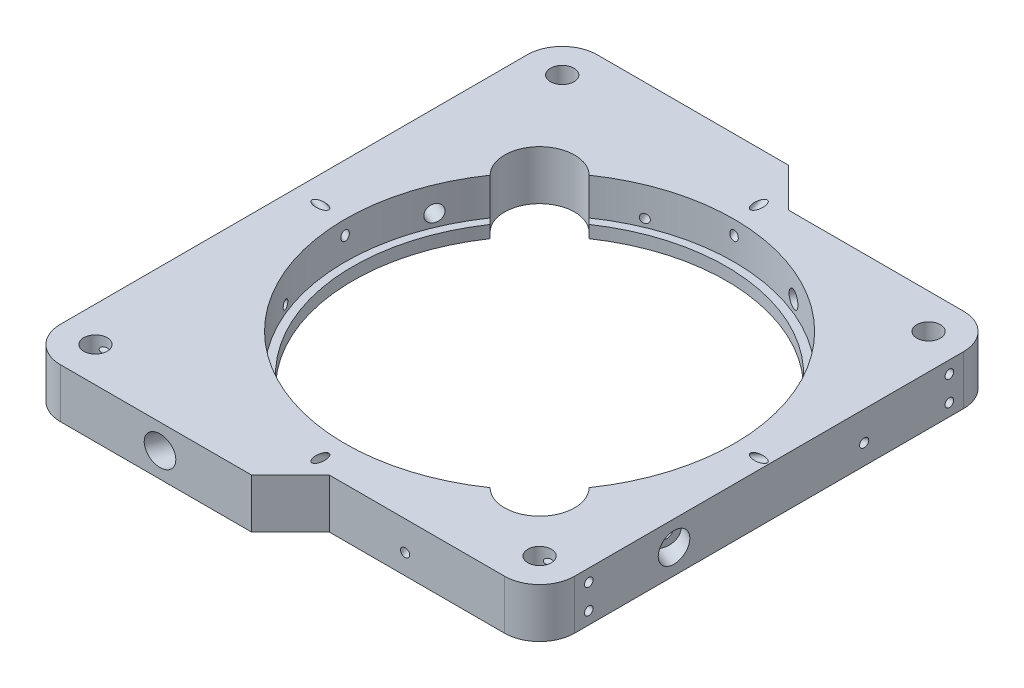
from build123d import *

# Parameters (mm, degrees)
SKETCH1_R                           = 3.025
BOSS_EXTRUDE1_DEPTH                 = 12.7
SKETCH2_R                           = 1.095
CUT_EXTRUDE1_DEPTH                  = 15
SKETCH5_R                           = 2.1
CUT_EXTRUDE2_DEPTH                  = 95.415667708
SKETCH6_R                           = 1.095
CUT_EXTRUDE3_DEPTH                  = 95.415667708
CUT_EXTRUDE4_REACH                  = 134.175
SKETCH7_R                           = 1.095
CUT_EXTRUDE4_DIRECTION_2_REACH      = 134.175
CUT_EXTRUDE4_DIRECTION_2_END_RADIUS = 50
CIRPATTERN1_COUNT                   = 4
CUT_EXTRUDE5_DEPTH                  = 95.415667848
CIRPATTERN2_COUNT                   = 2
CUT_EXTRUDE6_START                  = -158.748997848
SKETCH9_R                           = 3.75
CUT_EXTRUDE6_DEPTH                  = 100.415667848
CIRPATTERN6_COUNT                   = 4
SKETCH10_R                          = 1.095
CUT_EXTRUDE7_DEPTH                  = 16


with BuildPart() as part:
    # Sketch1 → Boss-Extrude1 (new body)
    with BuildSketch(Plane(origin=(0, 0, 0), x_dir=(1, 0, 0), z_dir=(0, 1, 0))):
        with BuildLine():
            Line((5, 59), (50, 59))
            ThreePointArc((50, 59), (56.363961031, 56.363961031), (59, 50))
            Line((59, 50), (59, -50))
            ThreePointArc((59, -50), (56.363961031, -56.363961031), (50, -59))
            Line((50, -59), (5, -59))
            Line((5, -59), (-5, -69))
            Line((-5, -69), (-54.1825, -69))
            ThreePointArc((-54.1825, -69), (-60.546461031, -66.363961031), (-63.1825, -60))
            Line((-63.1825, -60), (-63.1825, 60))
            ThreePointArc((-63.1825, 60), (-60.546461031, 66.363961031), (-54.1825, 69))
            Line((-54.1825, 69), (-5, 69))
            Line((-5, 69), (5, 59))
        make_face()
        with Locations(Location((50, 50, 0), (0, 0, 270))):
            Circle(SKETCH1_R, mode=Mode.SUBTRACT)
        with Locations(Location((50, -50, 0), (0, 0, 270))):
            Circle(SKETCH1_R, mode=Mode.SUBTRACT)
        with Locations(Location((-54.1825, 60, 0), (0, 0, 270))):
            Circle(SKETCH1_R, mode=Mode.SUBTRACT)
        with Locations(Location((-54.1825, -60, 0), (0, 0, 270))):
            Circle(SKETCH1_R, mode=Mode.SUBTRACT)
    extrude(amount=BOSS_EXTRUDE1_DEPTH)

    # Sketch2 → Cut-Extrude1 (cut)
    with BuildSketch(Plane(origin=(59, 0, 0), x_dir=(0, 0, -1), z_dir=(1, 0, 0))):
        with Locations((-46.34, 9.525)):
            Circle(SKETCH2_R)
        with Locations((-46.34, 3.175)):
            Circle(SKETCH2_R)
        with Locations((46.34, 9.525)):
            Circle(SKETCH2_R)
        with Locations((46.34, 3.175)):
            Circle(SKETCH2_R)
    extrude(amount=-CUT_EXTRUDE1_DEPTH, mode=Mode.SUBTRACT)

    # Sketch4 → Cut-Revolve1 (revolve, cut)
    with BuildSketch(Plane.XY):
        Polygon((0, 0), (0, 12.7), (50, 12.7), (50, 3.175), (48, 3.175), (48, 0), align=None)
    revolve(axis=Axis((0, 0, 0), (0, 1, 0)), mode=Mode.SUBTRACT)

    # Sketch5 → Cut-Extrude2 (cut, through all)
    with BuildSketch(Plane(origin=(0, 0, 0), x_dir=(0.9238795325112865, 0, 0.3826834323650906), z_dir=(-0.38268343236509056, 0, 0.9238795325112864))):
        with Locations((0, 6.35)):
            Circle(SKETCH5_R)
    cut_extrude2 = extrude(amount=-CUT_EXTRUDE2_DEPTH, mode=Mode.SUBTRACT)

    # Sketch6 → Cut-Extrude3 (cut, through all)
    with BuildSketch(Plane(origin=(0, 0, 0), x_dir=(0.3826834323650874, 0, 0.9238795325112878), z_dir=(-0.9238795325112878, 0, 0.3826834323650874))):
        with Locations((0, 5.175)):
            Circle(SKETCH6_R)
    cut_extrude3 = extrude(amount=-CUT_EXTRUDE3_DEPTH, mode=Mode.SUBTRACT)

    # Cut-Extrude4: up to this plane
    cut_extrude4_end = Plane(origin=(-54.1825, 12.7, -60), z_dir=(0, 1, 0))
    # Sketch7 → Cut-Extrude4 (cut, up to the surface)
    with BuildSketch(Plane(origin=(0, 25.547749412, 44.25), x_dir=(-1, 0, 0), z_dir=(0, -0.500000000000001, -0.866025403784438)), mode=Mode.PRIVATE) as cut_extrude4_sk1:
        with Locations(Location((0, -17.176477372, 0), (0, 0, 90))):
            Circle(SKETCH7_R)
    cut_extrude4_tool1 = split(extrude(cut_extrude4_sk1.sketch, amount=-CUT_EXTRUDE4_REACH, mode=Mode.PRIVATE), bisect_by=cut_extrude4_end, keep=Keep.BOTH, mode=Mode.PRIVATE)
    cut_extrude4 = cut_extrude4_tool1.solids().sort_by_distance((0, 10.672484, 52.838239))[0]
    add(cut_extrude4, mode=Mode.SUBTRACT)

    # Cut-Extrude4 direction 2: up to this cylinder (the profile starts outside it)
    cut_extrude4_direction_2_end = Plane(origin=(0, 10.672484, 0), z_dir=(0, -1, 0)) * Cylinder(CUT_EXTRUDE4_DIRECTION_2_END_RADIUS, 369.35, mode=Mode.PRIVATE)
    # Sketch7 → Cut-Extrude4 direction 2 (cut, up to the surface)
    with BuildSketch(Plane(origin=(0, 25.547749412, 44.25), x_dir=(-1, 0, 0), z_dir=(0, -0.500000000000001, -0.866025403784438)), mode=Mode.PRIVATE) as cut_extrude4_direction_2_sk1:
        with Locations(Location((0, -17.176477372, 0), (0, 0, 90))):
            Circle(SKETCH7_R)
    cut_extrude4_direction_2_tool1 = extrude(cut_extrude4_direction_2_sk1.sketch, amount=CUT_EXTRUDE4_DIRECTION_2_REACH, mode=Mode.PRIVATE) - cut_extrude4_direction_2_end
    cut_extrude4_direction_2 = cut_extrude4_direction_2_tool1.solids().sort_by_distance((0, 10.672484, 52.838239))[0]
    add(cut_extrude4_direction_2, mode=Mode.SUBTRACT)
    cut_extrude4 = cut_extrude4 + cut_extrude4_direction_2  # both directions under the feature's name, for the pattern or mirror that repeats it

    # CirPattern1: Cut-Extrude2, Cut-Extrude3, Cut-Extrude4 ×4 about axis
    cirpattern1_axis = Axis((0, 13.335, 0), (0, -1, 0))
    add([cut_extrude2.rotate(cirpattern1_axis, i * 360 / CIRPATTERN1_COUNT) for i in range(1, CIRPATTERN1_COUNT)], mode=Mode.SUBTRACT)
    add([cut_extrude3.rotate(cirpattern1_axis, i * 360 / CIRPATTERN1_COUNT) for i in range(1, CIRPATTERN1_COUNT)], mode=Mode.SUBTRACT)
    add([cut_extrude4.rotate(cirpattern1_axis, i * 360 / CIRPATTERN1_COUNT) for i in range(1, CIRPATTERN1_COUNT)], mode=Mode.SUBTRACT)

    # Sketch8 → Cut-Extrude5 (cut, through all)
    with BuildSketch(Plane(origin=(0, 12.7, 0), x_dir=(1, 0, 0), z_dir=(0, 1, 0))):
        with BuildLine():
            Line((-41.141827555, 28.413905494), (-39.703127187, 26.975205126))
            Line((-39.703127187, 26.975205126), (-26.975205126, 39.703127187))
            Line((-26.975205126, 39.703127187), (-28.413905494, 41.141827555))
            ThreePointArc((-28.413905494, 41.141827555), (-41.141827555, 41.141827555), (-41.141827555, 28.413905494))
        make_face()
    cut_extrude5 = extrude(amount=-CUT_EXTRUDE5_DEPTH, mode=Mode.SUBTRACT)

    # CirPattern2: Cut-Extrude5 ×2 about axis
    cirpattern2_axis = Axis((0, 0, 0), (0, 1, 0))
    for i in range(1, CIRPATTERN2_COUNT):
        add(cut_extrude5.rotate(cirpattern2_axis, i * 360 / CIRPATTERN2_COUNT), mode=Mode.SUBTRACT)

    # Sketch9 → Cut-Extrude6 (cut)
    with BuildSketch(Plane(origin=(0, 0, 0), x_dir=(0.9238795325112865, 0, 0.3826834323650906), z_dir=(-0.38268343236509056, 0, 0.9238795325112864)).offset(CUT_EXTRUDE6_START)):
        with Locations((0, 6.35)):
            Circle(SKETCH9_R)
    cut_extrude6 = extrude(amount=CUT_EXTRUDE6_DEPTH, mode=Mode.SUBTRACT)

    # CirPattern6: Cut-Extrude6 ×4 about axis
    cirpattern6_axis = Axis((0, 0, 0), (0, 1, 0))
    for i in range(1, CIRPATTERN6_COUNT):
        add(cut_extrude6.rotate(cirpattern6_axis, i * 360 / CIRPATTERN6_COUNT), mode=Mode.SUBTRACT)

    # Sketch10 → Cut-Extrude7 (cut)
    with BuildSketch(Plane.ZY.offset(63.1825)):
        with Locations((56.34, 9.525)):
            Circle(SKETCH10_R)
        with Locations((56.34, 3.175)):
            Circle(SKETCH10_R)
        with Locations((-56.34, 9.525)):
            Circle(SKETCH10_R)
        with Locations((-56.34, 3.175)):
            Circle(SKETCH10_R)
    extrude(amount=-CUT_EXTRUDE7_DEPTH, mode=Mode.SUBTRACT)


solid = part.part
